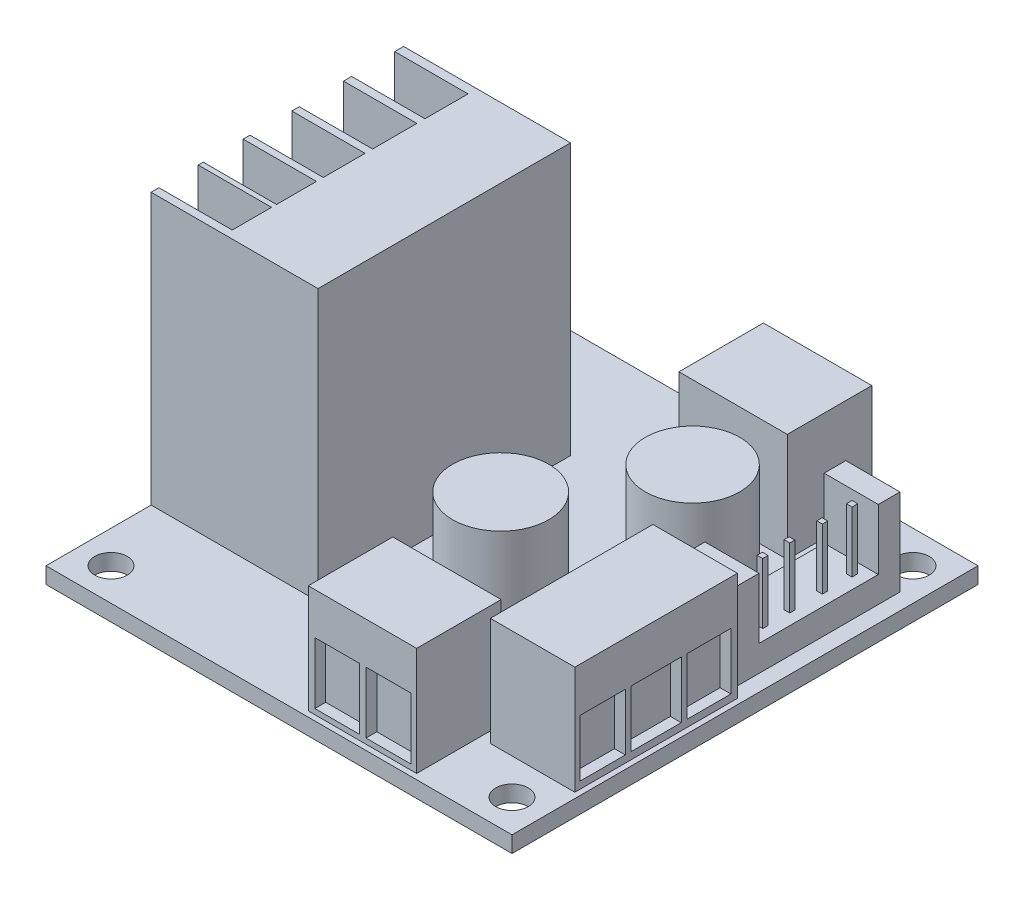
from build123d import *

# Parameters (mm, degrees)
SKETCH_1_W          = 43
SKETCH_1_H          = 43
EXTRUDE_1_DEPTH     = 1.5
SKETCH_2_W          = 7.8
SKETCH_2_H          = 15
EXTRUDE_2_DEPTH     = 10
SKETCH_2_W_2        = 10
SKETCH_2_H_2        = 7.8
EXTRUDE_2_2_DEPTH   = 10
EXTRUDE_2_3_DEPTH   = 10
SKETCH_3_W          = 15.4
SKETCH_3_H          = 23.3
EXTRUDE_3_DEPTH     = 25
SKETCH_4_W          = 6.764705707
SKETCH_4_H          = 3.97162229
SKETCH_4_H_2        = 4.086741777
SKETCH_4_H_3        = 3.856502803
SKETCH_4_H_4        = 3.683823573
SKETCH_4_H_5        = 3.626263829
CUT_EXTRUDE_1_DEPTH = 25
SKETCH_5_R          = 4.359395477
EXTRUDE_4_DEPTH     = 10
SKETCH_5_R_2        = 4.435881934
EXTRUDE_4_2_DEPTH   = 10
SKETCH_6_W          = 4.180930447
SKETCH_6_H          = 5.248402051
SKETCH_6_W_2        = 4.625710282
SKETCH_6_W_3        = 4.047496497
CUT_EXTRUDE_2_DEPTH = 1
SKETCH_8_W          = 4.105878298
SKETCH_8_H          = 5.668563322
SKETCH_8_W_2        = 4.136519181
CUT_EXTRUDE_3_DEPTH = 1
SKETCH_9_W          = 4.199646783
SKETCH_9_H          = 5.634969101
SKETCH_9_W_2        = 3.774366096
CUT_EXTRUDE_4_DEPTH = 1
SKETCH_10_R         = 1.5
CUT_EXTRUDE_5_DEPTH = 3
SKETCH_11_W         = 5
SKETCH_11_H         = 15
EXTRUDE_5_DEPTH     = 2.4
SKETCH_12_W         = 5
SKETCH_12_H         = 2
EXTRUDE_6_DEPTH     = 5.6
SKETCH_13_W         = 0.520232118
SKETCH_13_H         = 0.520232118
EXTRUDE_7_DEPTH     = 5.6
SKETCH_13_H_2       = 0.492851481
EXTRUDE_7_2_DEPTH   = 5.6
SKETCH_13_H_3       = 0.465470842
EXTRUDE_7_3_DEPTH   = 5.6
SKETCH_13_H_4       = 0.49285148
EXTRUDE_7_4_DEPTH   = 5.6


with BuildPart() as part:
    # 草圖1 → 填料-伸長1 (new body)
    with BuildSketch(Plane(origin=(0, 0, 0), x_dir=(1, 0, 0), z_dir=(0, 1, 0))):
        with Locations((21.5, 21.5)):
            Rectangle(SKETCH_1_W, SKETCH_1_H)
    extrude(amount=EXTRUDE_1_DEPTH)

    # 草圖10 → 除料-伸長5 (cut)
    with BuildSketch(Plane.XZ):
        with Locations((40, -3)):
            Circle(SKETCH_10_R)
        with Locations((3, -3)):
            Circle(SKETCH_10_R)
        with Locations((3, -40)):
            Circle(SKETCH_10_R)
        with Locations((40, -40)):
            Circle(SKETCH_10_R)
    extrude(amount=-CUT_EXTRUDE_5_DEPTH, mode=Mode.SUBTRACT)


with BuildPart() as body_2:
    # 草圖2 → 填料-伸長2 (new body)
    with BuildSketch(Plane(origin=(0, 1.5, 0), x_dir=(1, 0, 0), z_dir=(0, 1, 0))):
        with Locations((38.6, 13.8)):
            Rectangle(SKETCH_2_W, SKETCH_2_H)
    extrude(amount=EXTRUDE_2_DEPTH)

    # 草圖6 → 除料-伸長2 (cut)
    with BuildSketch(Plane(origin=(42.5, 0, 0), x_dir=(0, 0, -1), z_dir=(1, 0, 0))):
        with Locations((8.868252691, 4.776944146)):
            Rectangle(SKETCH_6_W, SKETCH_6_H)
        with Locations((13.805308857, 4.776944146)):
            Rectangle(SKETCH_6_W_2, SKETCH_6_H)
        with Locations((18.675648049, 4.776944146)):
            Rectangle(SKETCH_6_W_3, SKETCH_6_H)
    extrude(amount=-CUT_EXTRUDE_2_DEPTH, mode=Mode.SUBTRACT)


with BuildPart() as body_3:
    # 草圖2 → Extrude 2 2 (new body)
    with BuildSketch(Plane(origin=(0, 1.5, 0), x_dir=(1, 0, 0), z_dir=(0, 1, 0))):
        with Locations((28.7, 4.4)):
            Rectangle(SKETCH_2_W_2, SKETCH_2_H_2)
    extrude(amount=EXTRUDE_2_2_DEPTH)

    # 草圖8 → 除料-伸長3 (cut)
    with BuildSketch(Plane.XY.offset(-0.5)):
        with Locations((26.358920359, 4.827651605)):
            Rectangle(SKETCH_8_W, SKETCH_8_H)
        with Locations((31.092936755, 4.827651605)):
            Rectangle(SKETCH_8_W_2, SKETCH_8_H)
    extrude(amount=-CUT_EXTRUDE_3_DEPTH, mode=Mode.SUBTRACT)


with BuildPart() as body_4:
    # 草圖2 → Extrude 2 3 (new body)
    with BuildSketch(Plane(origin=(0, 1.5, 0), x_dir=(1, 0, 0), z_dir=(0, 1, 0))):
        with Locations((28.7, 38.6)):
            Rectangle(SKETCH_2_W_2, SKETCH_2_H_2)
    extrude(amount=EXTRUDE_2_3_DEPTH)

    # 草圖9 → 除料-伸長4 (cut)
    with BuildSketch(Plane(origin=(0, 0, -42.5), x_dir=(-1, 0, 0), z_dir=(0, 0, -1))):
        with Locations((-30.888679621, 4.943816645)):
            Rectangle(SKETCH_9_W, SKETCH_9_H)
        with Locations((-26.210592066, 4.943816645)):
            Rectangle(SKETCH_9_W_2, SKETCH_9_H)
    extrude(amount=-CUT_EXTRUDE_4_DEPTH, mode=Mode.SUBTRACT)


with BuildPart() as body_5:
    # 草圖3 → 填料-伸長3 (new body)
    with BuildSketch(Plane(origin=(0, 1.5, 0), x_dir=(1, 0, 0), z_dir=(0, 1, 0))):
        with Locations((7.7, 21.35)):
            Rectangle(SKETCH_3_W, SKETCH_3_H)
    extrude(amount=EXTRUDE_3_DEPTH)

    # 草圖4 → 除料-伸長1 (cut)
    with BuildSketch(Plane(origin=(0, 26.5, 0), x_dir=(1, 0, 0), z_dir=(0, 1, 0))):
        with Locations((3.382352854, 30.191521243)):
            Rectangle(SKETCH_4_W, SKETCH_4_H)
        with Locations((3.382352854, 25.414062547)):
            Rectangle(SKETCH_4_W, SKETCH_4_H_2)
        with Locations((3.382352854, 20.751723336)):
            Rectangle(SKETCH_4_W, SKETCH_4_H_3)
        with Locations((3.382352854, 16.348402972)):
            Rectangle(SKETCH_4_W, SKETCH_4_H_4)
        with Locations((3.382352854, 12.232881324)):
            Rectangle(SKETCH_4_W, SKETCH_4_H_5)
    extrude(amount=-CUT_EXTRUDE_1_DEPTH, mode=Mode.SUBTRACT)


with BuildPart() as body_6:
    # 草圖5 → 填料-伸長4 (new body)
    with BuildSketch(Plane(origin=(0, 1.5, 0), x_dir=(1, 0, 0), z_dir=(0, 1, 0))):
        with Locations((31.744713357, 27.915378753)):
            Circle(SKETCH_5_R)
    extrude(amount=EXTRUDE_4_DEPTH)


with BuildPart() as body_7:
    # 草圖5 → Extrude 4 2 (new body)
    with BuildSketch(Plane(origin=(0, 1.5, 0), x_dir=(1, 0, 0), z_dir=(0, 1, 0))):
        with Locations((25.080676513, 16.874959504)):
            Circle(SKETCH_5_R_2)
    extrude(amount=EXTRUDE_4_2_DEPTH)


with BuildPart() as body_8:
    # 草圖11 → 填料-伸長5 (new body)
    with BuildSketch(Plane(origin=(0, 1.5, 0), x_dir=(1, 0, 0), z_dir=(0, 1, 0))):
        with Locations((39, 29.8)):
            Rectangle(SKETCH_11_W, SKETCH_11_H)
    extrude(amount=EXTRUDE_5_DEPTH)

    # 草圖12 → 填料-伸長6 (add)
    with BuildSketch(Plane(origin=(0, 3.9, 0), x_dir=(1, 0, 0), z_dir=(0, 1, 0))):
        with Locations((39, 36.3)):
            Rectangle(SKETCH_12_W, SKETCH_12_H)
        with Locations((39, 23.3)):
            Rectangle(SKETCH_12_W, SKETCH_12_H)
    extrude(amount=EXTRUDE_6_DEPTH)


with BuildPart() as body_9:
    # 草圖13 → 填料-伸長7 (new body)
    with BuildSketch(Plane(origin=(0, 3.9, 0), x_dir=(1, 0, 0), z_dir=(0, 1, 0))):
        with Locations((40.230628725, 34.147639552)):
            Rectangle(SKETCH_13_W, SKETCH_13_H)
    extrude(amount=EXTRUDE_7_DEPTH)


with BuildPart() as body_10:
    # 草圖13 → Extrude 7 2 (new body)
    with BuildSketch(Plane(origin=(0, 3.9, 0), x_dir=(1, 0, 0), z_dir=(0, 1, 0))):
        with Locations((40.230628725, 31.395885455)):
            Rectangle(SKETCH_13_W, SKETCH_13_H_2)
    extrude(amount=EXTRUDE_7_2_DEPTH)


with BuildPart() as body_11:
    # 草圖13 → Extrude 7 3 (new body)
    with BuildSketch(Plane(origin=(0, 3.9, 0), x_dir=(1, 0, 0), z_dir=(0, 1, 0))):
        with Locations((40.230628725, 28.370324979)):
            Rectangle(SKETCH_13_W, SKETCH_13_H_3)
    extrude(amount=EXTRUDE_7_3_DEPTH)


with BuildPart() as body_12:
    # 草圖13 → Extrude 7 4 (new body)
    with BuildSketch(Plane(origin=(0, 3.9, 0), x_dir=(1, 0, 0), z_dir=(0, 1, 0))):
        with Locations((40.230628725, 25.892377259)):
            Rectangle(SKETCH_13_W, SKETCH_13_H_4)
    extrude(amount=EXTRUDE_7_4_DEPTH)


solid = Compound([part.part, body_2.part, body_3.part, body_4.part, body_5.part, body_6.part, body_7.part, body_8.part, body_9.part, body_10.part, body_11.part, body_12.part])
